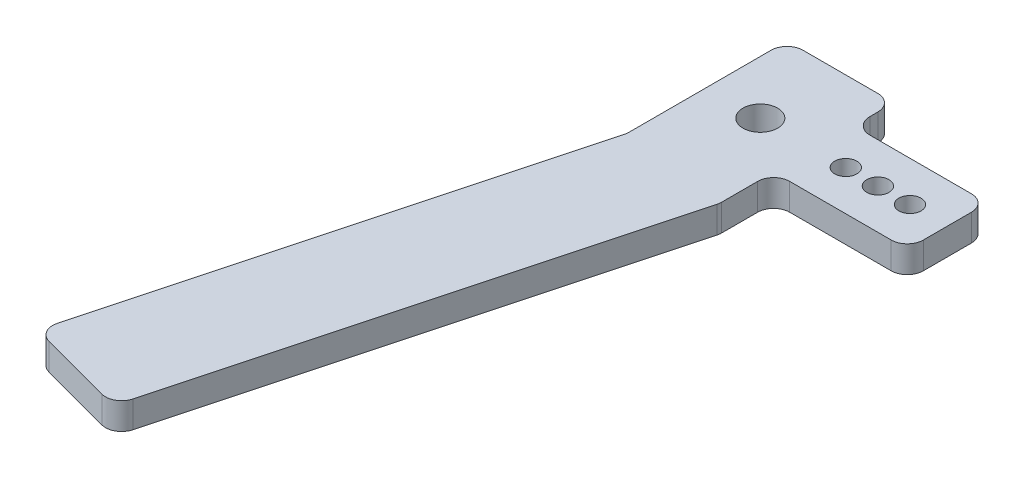
from build123d import *

# Parameters (mm, degrees)
SKETCH1_R           = 3.25
BOSS_EXTRUDE1_DEPTH = 5
SKETCH2_R           = 2.075
BOSS_EXTRUDE2_DEPTH = 5
FILLET1_R           = 3


with BuildPart() as part:
    # Sketch1 → Boss-Extrude1 (new body)
    with BuildSketch(Plane(origin=(0, 0, 0), x_dir=(1, 0, 0), z_dir=(0, 1, 0))):
        Polygon((-59.15, -15), (-82.443714059, -101.933324366), (-63.125197533, -107.109705268), (-39.831483474, -20.176380902), (-39.15, -17.633049952), (-39.15, -15), (-39.15, 15), (-59.15, 15), align=None)
        with Locations((-49.15, 0)):
            Circle(SKETCH1_R, mode=Mode.SUBTRACT)
    extrude(amount=BOSS_EXTRUDE1_DEPTH)

    # Sketch2 → Boss-Extrude2 (add)
    with BuildSketch(Plane.XZ):
        Polygon((-14.15, -7.5), (-14.15, 7.5), (-27.15, 7.5), (-33.15, 7.5), (-39.15, 7.5), (-39.15, -7.5), align=None)
        with Locations((-33.15, 0)):
            Circle(SKETCH2_R, mode=Mode.SUBTRACT)
        with Locations((-27.15, 0)):
            Circle(SKETCH2_R, mode=Mode.SUBTRACT)
        with Locations((-21.15, 0)):
            Circle(SKETCH2_R, mode=Mode.SUBTRACT)
    extrude(amount=-BOSS_EXTRUDE2_DEPTH)

    # Fillet1
    fillet1_edges = [part.edges().sort_by_distance(p)[0] for p in [
        (-39.15, 2.5, 17.633049952),
        (-63.125197533, 2.5, 107.109705268),
        (-82.443714059, 2.5, 101.933324366),
        (-59.15, 2.5, 15),
        (-59.15, 2.5, -15),
        (-39.15, 2.5, -15),
        (-14.15, 2.5, -7.5),
        (-39.15, 2.5, -7.5),
        (-39.15, 2.5, 7.5),
        (-14.15, 2.5, 7.5),
    ]]
    fillet(fillet1_edges, radius=FILLET1_R)


solid = part.part
